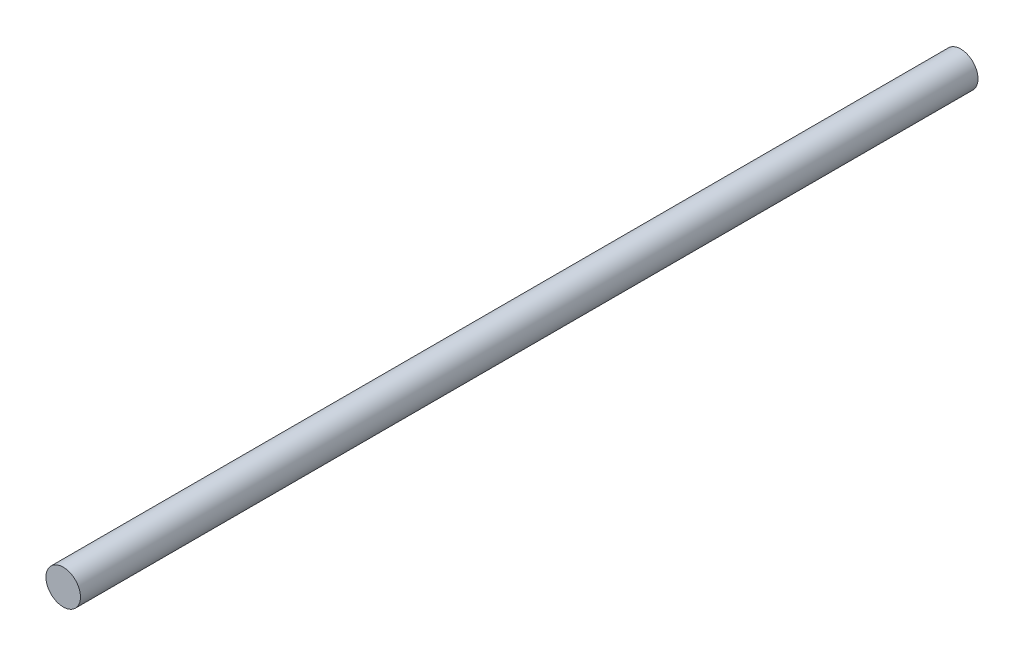
from build123d import *

# Parameters (mm, degrees)
SKETCH1_R           = 2
BOSS_EXTRUDE1_DEPTH = 104


with BuildPart() as part:
    # Sketch1 → Boss-Extrude1 (new body)
    with BuildSketch(Plane.XY):
        Circle(SKETCH1_R)
    extrude(amount=BOSS_EXTRUDE1_DEPTH)


solid = part.part
